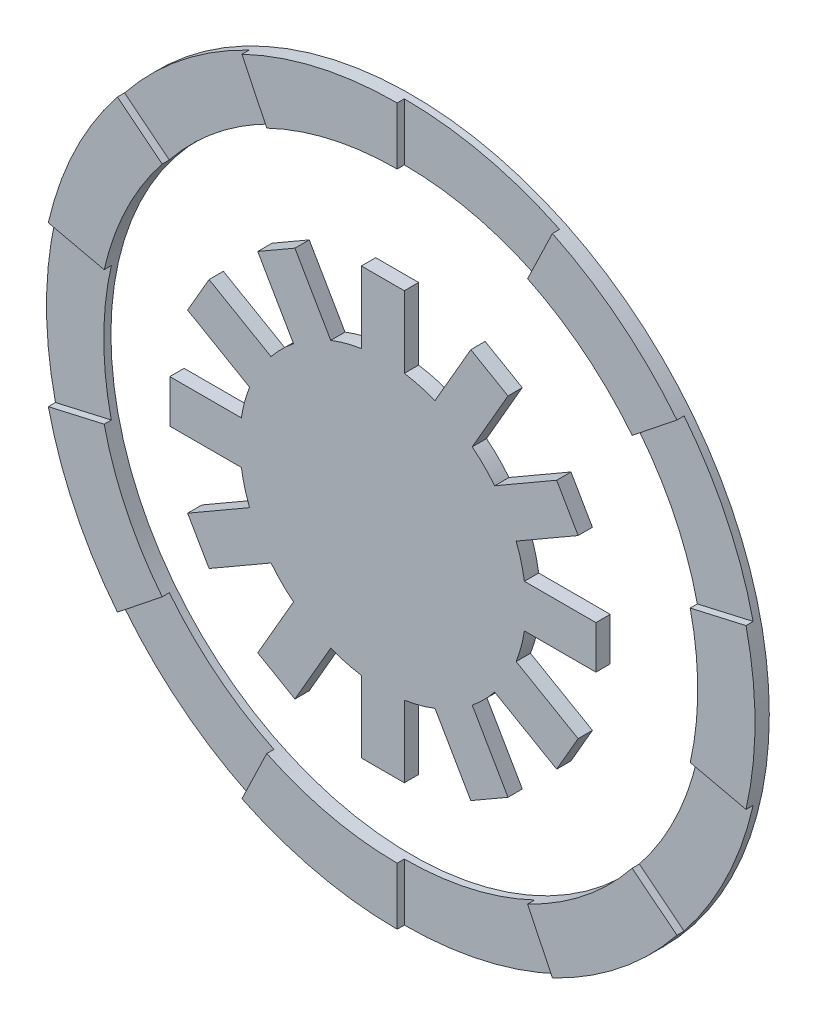
from build123d import *

# Parameters (mm, degrees)
SKETCH_1_R               = 50
SKETCH_1_R_2             = 42
EXTRUDE_1_DEPTH          = 2
CUT_EXTRUDE_1_DEPTH      = 1
PATTERN_CIRCULAR_1_COUNT = 7
SKETCH_3_R               = 20
EXTRUDE_2_DEPTH          = 2
EXTRUDE_3_DEPTH          = 2
PATTERN_CIRCULAR_2_COUNT = 12


with BuildPart() as part:
    # ｽｹｯﾁ1 → ﾎﾞｽ - 押し出し1 (new body)
    with BuildSketch(Plane.XY):
        Circle(SKETCH_1_R)
        Circle(SKETCH_1_R_2, mode=Mode.SUBTRACT)
    extrude(amount=EXTRUDE_1_DEPTH)

    # ｽｹｯﾁ2 → ｶｯﾄ - 押し出し1 (cut)
    with BuildSketch(Plane.XY.offset(2)):
        with BuildLine():
            Line((0, 50), (0, 42))
            ThreePointArc((0, 42), (9.345879226, 40.946972312), (18.223117043, 37.840692452))
            Line((18.223117043, 37.840692452), (21.694186956, 45.048443395))
            ThreePointArc((21.694186956, 45.048443395), (11.126046698, 48.746395609), (0, 50))
        make_face()
    cut_extrude_1 = extrude(amount=-CUT_EXTRUDE_1_DEPTH, mode=Mode.SUBTRACT)

    # 円形ﾊﾟﾀｰﾝ1: ｶｯﾄ - 押し出し1 ×7 about axis
    pattern_circular_1_axis = Axis((0, 0, 0), (0, 0, 1))
    for i in range(1, PATTERN_CIRCULAR_1_COUNT):
        add(cut_extrude_1.rotate(pattern_circular_1_axis, i * 360 / PATTERN_CIRCULAR_1_COUNT), mode=Mode.SUBTRACT)


with BuildPart() as body_2:
    # ｽｹｯﾁ3 → ﾎﾞｽ - 押し出し2 (new body)
    with BuildSketch(Plane.XY.offset(2)):
        Circle(SKETCH_3_R)
    extrude(amount=EXTRUDE_2_DEPTH)

    # ｽｹｯﾁ4 → ﾎﾞｽ - 押し出し3 (add)
    with BuildSketch(Plane.XY.offset(4)):
        with BuildLine():
            Line((3, 29.773719933), (-3, 29.773719933))
            Line((-3, 29.773719933), (-3, 19.773719933))
            ThreePointArc((-3, 19.773719933), (0, 20), (3, 19.773719933))
            Line((3, 19.773719933), (3, 29.773719933))
        make_face()
    extrude_3 = extrude(amount=-EXTRUDE_3_DEPTH)

    # 円形ﾊﾟﾀｰﾝ2: ﾎﾞｽ - 押し出し3 ×12 about axis
    pattern_circular_2_axis = Axis((0, 0, 0), (0, 0, 1))
    for i in range(1, PATTERN_CIRCULAR_2_COUNT):
        add(extrude_3.rotate(pattern_circular_2_axis, i * 360 / PATTERN_CIRCULAR_2_COUNT))


solid = Compound([part.part, body_2.part])
